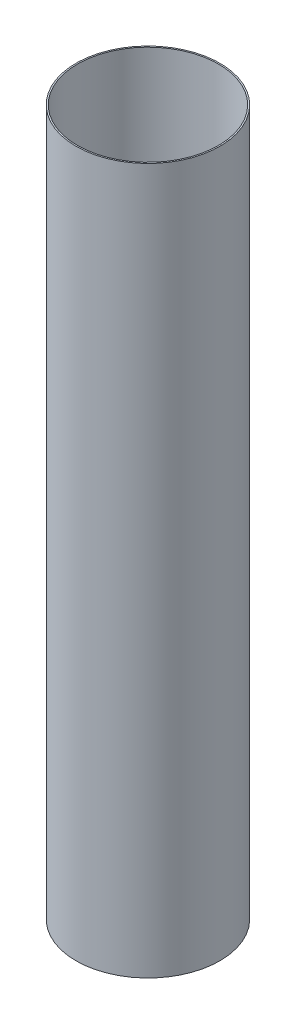
from build123d import *

# Parameters (mm, degrees)
CROQUIS1_R              = 153
CROQUIS1_R_2            = 150
SALIENTE_EXTRUIR1_DEPTH = 1500


with BuildPart() as part:
    # Croquis1 → Saliente-Extruir1 (new body)
    with BuildSketch(Plane(origin=(0, 0, 0), x_dir=(1, 0, 0), z_dir=(0, 1, 0))):
        Circle(CROQUIS1_R)
        Circle(CROQUIS1_R_2, mode=Mode.SUBTRACT)
    extrude(amount=SALIENTE_EXTRUIR1_DEPTH)


solid = part.part
